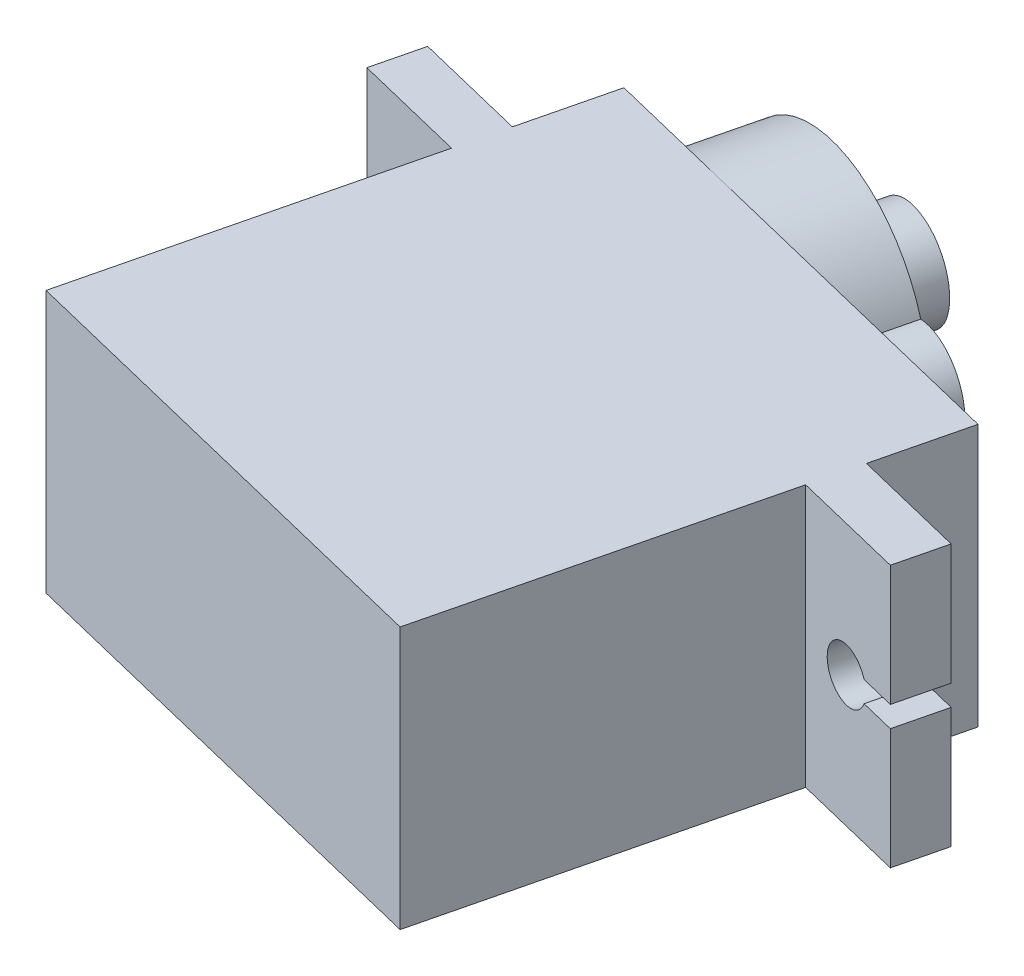
from build123d import *

# Parameters (mm, degrees)
BOSS_EXTRUDE1_DEPTH = 12.5
SKETCH2_R           = 6.25
SKETCH2_R_2         = 2.4
BOSS_EXTRUDE2_DEPTH = 4.4
SKETCH3_R           = 2.4
BOSS_EXTRUDE3_DEPTH = 3.2
SKETCH4_R           = 1.25
CUT_EXTRUDE1_DEPTH  = 3.2
CUT_EXTRUDE2_DEPTH  = 3.2


with BuildPart() as part:
    # Sketch1 → Boss-Extrude1 (new body)
    with BuildSketch(Plane(origin=(0, 0, 0), x_dir=(1, 0, 0), z_dir=(0, 1, 0))):
        Polygon((-7.197362046, -11.706627962), (15.14596589, -17.163339125), (18.941938873, -1.620154473), (24.284908597, -2.925020186), (24.854304545, -0.593542489), (19.511334821, 0.711323224), (20.555227391, 4.985699003), (-1.788100545, 10.442410167), (-2.831993116, 6.168034388), (-8.17496284, 7.472900101), (-8.744358787, 5.141422403), (-3.401389063, 3.83655669), align=None)
    extrude(amount=BOSS_EXTRUDE1_DEPTH)

    # Sketch2 → Boss-Extrude2 (add)
    with BuildSketch(Plane(origin=(2.306064383, 0, -9.442528881), x_dir=(-0.971449041, 0, -0.237248311), z_dir=(0.237248311, 0, -0.971449041))):
        with Locations((-2.035507261, 6.25)):
            Circle(SKETCH2_R)
        with Locations((-8.285507261, 6.25)):
            Circle(SKETCH2_R_2)
    extrude(amount=BOSS_EXTRUDE2_DEPTH)

    # Sketch3 → Boss-Extrude3 (add)
    with BuildSketch(Plane(origin=(3.349956953, 0, -13.71690466), x_dir=(-0.971449041, 0, -0.237248311), z_dir=(0.237248311, 0, -0.971449041))):
        with Locations((-2.035507261, 6.25)):
            Circle(SKETCH3_R)
    extrude(amount=BOSS_EXTRUDE3_DEPTH)

    # Sketch4 → Cut-Extrude1 (cut)
    with BuildSketch(Plane(origin=(1.262171813, 0, -5.168153102), x_dir=(-0.971449041, 0, -0.237248311), z_dir=(0.237248311, 0, -0.971449041))):
        with Locations((-21.435507261, 6.25)):
            Circle(SKETCH4_R)
        Polygon((-24.285507261, 6.25), (-24.285507261, 6.75), (-22.581151185, 6.75), (-22.581151185, 5.75), (-24.285507261, 5.75), align=None)
    extrude(amount=-CUT_EXTRUDE1_DEPTH, mode=Mode.SUBTRACT)

    # Sketch5 → Cut-Extrude2 (cut)
    with BuildSketch(Plane(origin=(1.262171813, 0, -5.168153102), x_dir=(-0.971449041, 0, -0.237248311), z_dir=(0.237248311, 0, -0.971449041))):
        with BuildLine():
            ThreePointArc((8.358804544, 6.75), (6.611198873, 7.805252387), (5.288749178, 6.25))
            Line((5.288749178, 6.25), (6.864492739, 6.25))
            Line((6.864492739, 6.25), (7.879253637, 6.25))
            Line((7.879253637, 6.25), (7.879253637, 6.75))
            Line((7.879253637, 6.75), (8.358804544, 6.75))
        make_face()
        with BuildLine():
            Line((6.864492739, 6.25), (5.288749178, 6.25))
            ThreePointArc((5.288749178, 6.25), (6.611198873, 4.694747613), (8.358804544, 5.75))
            Line((8.358804544, 5.75), (7.879253637, 5.75))
            Line((7.879253637, 5.75), (7.879253637, 6.25))
            Line((7.879253637, 6.25), (6.864492739, 6.25))
        make_face()
        with BuildLine():
            ThreePointArc((8.4402363, 6.25), (8.419745126, 5.996706134), (8.358804544, 5.75))
            Line((8.358804544, 5.75), (9.714492739, 5.75))
            Line((9.714492739, 5.75), (9.714492739, 6.25))
            Line((9.714492739, 6.25), (8.4402363, 6.25))
        make_face()
        with BuildLine():
            Line((9.714492739, 6.75), (8.358804544, 6.75))
            ThreePointArc((8.358804544, 6.75), (8.419745126, 6.503293866), (8.4402363, 6.25))
            Line((8.4402363, 6.25), (9.714492739, 6.25))
            Line((9.714492739, 6.25), (9.714492739, 6.75))
        make_face()
        with BuildLine():
            ThreePointArc((8.4402363, 6.25), (8.419745126, 6.503293866), (8.358804544, 6.75))
            Line((8.358804544, 6.75), (7.879253637, 6.75))
            Line((7.879253637, 6.75), (7.879253637, 6.25))
            Line((7.879253637, 6.25), (8.4402363, 6.25))
        make_face()
        with BuildLine():
            Line((7.879253637, 5.75), (8.358804544, 5.75))
            ThreePointArc((8.358804544, 5.75), (8.419745126, 5.996706134), (8.4402363, 6.25))
            Line((8.4402363, 6.25), (7.879253637, 6.25))
            Line((7.879253637, 6.25), (7.879253637, 5.75))
        make_face()
    extrude(amount=-CUT_EXTRUDE2_DEPTH, mode=Mode.SUBTRACT)


solid = part.part
